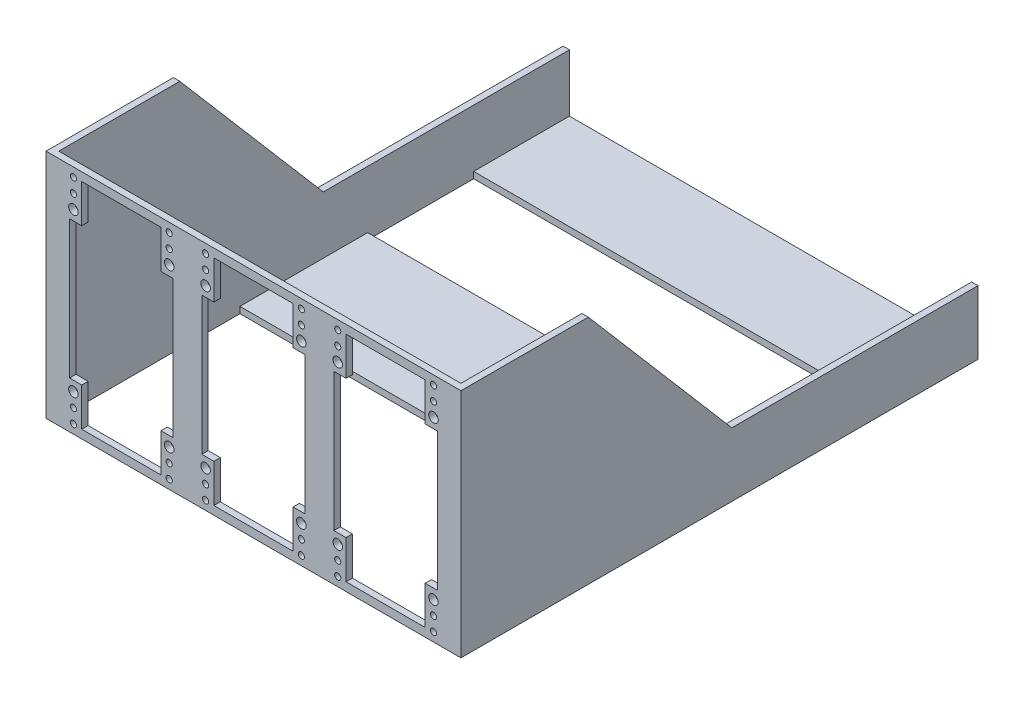
from build123d import *

# Parameters (mm, degrees)
SKETCH1_W               = 165.1
SKETCH1_H               = 92.075
BOSS_EXTRUDE1_DEPTH     = 2.54
SKETCH2_R               = 1.905
SKETCH2_R_2             = 1.2192
CUT_EXTRUDE1_DEPTH      = 2.54
SKETCH4_W               = 2.54
SKETCH4_H               = 92.075
BOSS_EXTRUDE3_DEPTH     = 203.2
SKETCH6_W               = 38.1
SKETCH6_H               = 2.54
BOSS_EXTRUDE4_DEPTH     = 160.02
SKETCH7_W               = 160.02
SKETCH7_H               = 50.8
BOSS_EXTRUDE5_DEPTH     = 2.54
CUT_EXTRUDE2_DEPTH      = 1
CUT_EXTRUDE2_DEPTH_BACK = 166.1


with BuildPart() as part:
    # Sketch1 → Boss-Extrude1 (new body)
    with BuildSketch(Plane.XY):
        with Locations((259.660273445, 73.209654415)):
            Rectangle(SKETCH1_W, SKETCH1_H)
    extrude(amount=-BOSS_EXTRUDE1_DEPTH)

    # Sketch2 → Cut-Extrude1 (cut)
    with BuildSketch(Plane.XY):
        with Locations((188.032273445, 41.815254415)):
            Circle(SKETCH2_R)
        with Locations((226.132273445, 104.604054415)):
            Circle(SKETCH2_R)
        with Locations((188.032273445, 104.604054415)):
            Circle(SKETCH2_R)
        with Locations((188.032273445, 36.278054415)):
            Circle(SKETCH2_R_2)
        with Locations((188.032273445, 30.715454415)):
            Circle(SKETCH2_R_2)
        with Locations((226.132273445, 41.815254415)):
            Circle(SKETCH2_R)
        with Locations((226.132273445, 36.278054415)):
            Circle(SKETCH2_R_2)
        with Locations((226.132273445, 30.715454415)):
            Circle(SKETCH2_R_2)
        with Locations((226.132273445, 110.141254415)):
            Circle(SKETCH2_R_2)
        with Locations((226.132273445, 115.703854415)):
            Circle(SKETCH2_R_2)
        with Locations((188.032273445, 110.141254415)):
            Circle(SKETCH2_R_2)
        with Locations((188.032273445, 115.703854415)):
            Circle(SKETCH2_R_2)
        with Locations((240.610273445, 41.815254415)):
            Circle(SKETCH2_R)
        with Locations((278.710273445, 104.604054415)):
            Circle(SKETCH2_R)
        with Locations((240.610273445, 104.604054415)):
            Circle(SKETCH2_R)
        with Locations((240.610273445, 36.278054415)):
            Circle(SKETCH2_R_2)
        with Locations((240.610273445, 30.715454415)):
            Circle(SKETCH2_R_2)
        with Locations((278.710273445, 41.815254415)):
            Circle(SKETCH2_R)
        with Locations((278.710273445, 36.278054415)):
            Circle(SKETCH2_R_2)
        with Locations((278.710273445, 30.715454415)):
            Circle(SKETCH2_R_2)
        with Locations((278.710273445, 110.141254415)):
            Circle(SKETCH2_R_2)
        with Locations((278.710273445, 115.703854415)):
            Circle(SKETCH2_R_2)
        with Locations((240.610273445, 110.141254415)):
            Circle(SKETCH2_R_2)
        with Locations((240.610273445, 115.703854415)):
            Circle(SKETCH2_R_2)
        with Locations((293.188273445, 41.815254415)):
            Circle(SKETCH2_R)
        with Locations((331.288273445, 104.604054415)):
            Circle(SKETCH2_R)
        with Locations((293.188273445, 104.604054415)):
            Circle(SKETCH2_R)
        with Locations((293.188273445, 36.278054415)):
            Circle(SKETCH2_R_2)
        with Locations((293.188273445, 30.715454415)):
            Circle(SKETCH2_R_2)
        with Locations((331.288273445, 41.815254415)):
            Circle(SKETCH2_R)
        with Locations((331.288273445, 36.278054415)):
            Circle(SKETCH2_R_2)
        with Locations((331.288273445, 30.715454415)):
            Circle(SKETCH2_R_2)
        with Locations((331.288273445, 110.141254415)):
            Circle(SKETCH2_R_2)
        with Locations((331.288273445, 115.703854415)):
            Circle(SKETCH2_R_2)
        with Locations((293.188273445, 110.141254415)):
            Circle(SKETCH2_R_2)
        with Locations((293.188273445, 115.703854415)):
            Circle(SKETCH2_R_2)
        Polygon((191.334273445, 115.881654415), (222.830273445, 115.881654415), (222.830273445, 100.641654415), (227.656273445, 100.641654415), (227.656273445, 45.777654415), (222.830273445, 45.777654415), (222.830273445, 30.537654415), (191.334273445, 30.537654415), (191.334273445, 45.777654415), (186.508273445, 45.777654415), (186.508273445, 100.641654415), (191.334273445, 100.641654415), align=None)
        Polygon((243.912273445, 115.881654415), (275.408273445, 115.881654415), (275.408273445, 100.641654415), (280.234273445, 100.641654415), (280.234273445, 45.777654415), (275.408273445, 45.777654415), (275.408273445, 30.537654415), (243.912273445, 30.537654415), (243.912273445, 45.777654415), (239.086273445, 45.777654415), (239.086273445, 100.641654415), (243.912273445, 100.641654415), align=None)
        Polygon((296.490273445, 115.881654415), (327.986273445, 115.881654415), (327.986273445, 100.641654415), (332.812273445, 100.641654415), (332.812273445, 45.777654415), (327.986273445, 45.777654415), (327.986273445, 30.537654415), (296.490273445, 30.537654415), (296.490273445, 45.777654415), (291.664273445, 45.777654415), (291.664273445, 100.641654415), (296.490273445, 100.641654415), align=None)
    extrude(amount=-CUT_EXTRUDE1_DEPTH, mode=Mode.SUBTRACT)

    # Sketch4 → Boss-Extrude3 (add)
    with BuildSketch(Plane(origin=(0, 0, -2.54), x_dir=(-1, 0, 0), z_dir=(0, 0, -1))):
        with Locations((-340.940273445, 73.209654415)):
            Rectangle(SKETCH4_W, SKETCH4_H)
        with Locations((-178.380273445, 73.209654415)):
            Rectangle(SKETCH4_W, SKETCH4_H)
    extrude(amount=BOSS_EXTRUDE3_DEPTH)

    # Sketch6 → Boss-Extrude4 (add)
    with BuildSketch(Plane.ZY.offset(-339.670273445)):
        with Locations((-186.69, 28.442154415)):
            Rectangle(SKETCH6_W, SKETCH6_H)
    extrude(amount=BOSS_EXTRUDE4_DEPTH)

    # Sketch7 → Boss-Extrude5 (add)
    with BuildSketch(Plane.XZ.offset(-27.172154415)):
        with Locations((259.660273445, -100.037339466)):
            Rectangle(SKETCH7_W, SKETCH7_H)
    extrude(amount=-BOSS_EXTRUDE5_DEPTH)

    # Sketch8 → Cut-Extrude2 (cut, two sides)
    with BuildSketch(Plane(origin=(342.210273445, 0, 0), x_dir=(0, 0, -1), z_dir=(1, 0, 0))) as cut_extrude2_sk:
        Polygon((205.74, 119.247154415), (50.692993011, 119.247154415), (107.781148805, 52.572154415), (205.74, 52.572154415), align=None)
    extrude(amount=CUT_EXTRUDE2_DEPTH, mode=Mode.SUBTRACT)
    extrude(cut_extrude2_sk.sketch, amount=-CUT_EXTRUDE2_DEPTH_BACK, mode=Mode.SUBTRACT)


solid = part.part
